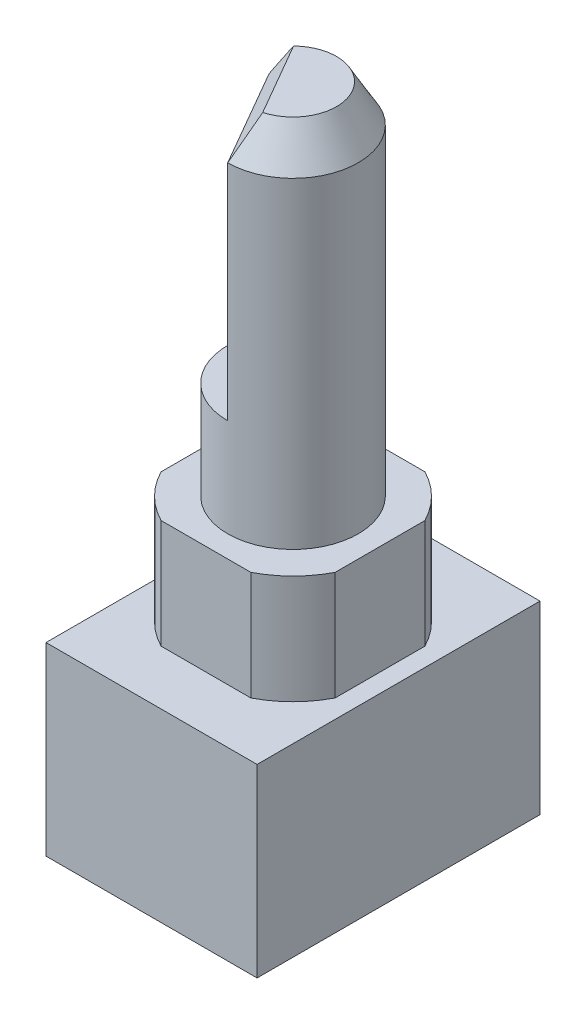
from build123d import *

# Parameters (mm, degrees)
SKETCH1_W           = 9.7
SKETCH1_H           = 13
BOSS_EXTRUDE1_DEPTH = 8.5
SKETCH2_R           = 4.5
BOSS_EXTRUDE2_DEPTH = 5
BOSS_EXTRUDE4_START = -5
SKETCH3_R           = 3
BOSS_EXTRUDE4_DEPTH = 21.5
CUT_EXTRUDE1_DEPTH  = 5
CUT_EXTRUDE2_DEPTH  = 12
CHAMFER1_SIZE       = 1
CHAMFER1_SIZE2      = 1.732050808


with BuildPart() as part:
    # Sketch1 → Boss-Extrude1 (new body)
    with BuildSketch(Plane(origin=(0, 0, 0), x_dir=(1, 0, 0), z_dir=(0, 1, 0))):
        Rectangle(SKETCH1_W, SKETCH1_H)
    extrude(amount=BOSS_EXTRUDE1_DEPTH)

    # Sketch2 → Boss-Extrude2 (add)
    with BuildSketch(Plane(origin=(0, 8.5, 0), x_dir=(1, 0, 0), z_dir=(0, 1, 0))):
        Circle(SKETCH2_R)
    extrude(amount=BOSS_EXTRUDE2_DEPTH)

    # Sketch3 → Boss-Extrude4 (add)
    with BuildSketch(Plane(origin=(0, 13.5, 0), x_dir=(1, 0, 0), z_dir=(0, 1, 0)).offset(BOSS_EXTRUDE4_START)):
        Circle(SKETCH3_R)
    extrude(amount=BOSS_EXTRUDE4_DEPTH)

    # Sketch4 → Cut-Extrude1 (cut)
    with BuildSketch(Plane(origin=(0, 13.5, 0), x_dir=(1, 0, 0), z_dir=(0, 1, 0))):
        with BuildLine():
            ThreePointArc((-4, 2.061552813), (-4.5, 0), (-4, -2.061552813))
            Line((-4, -2.061552813), (-4, 2.061552813))
        make_face()
        with BuildLine():
            ThreePointArc((-2.061552813, -4), (0, -4.5), (2.061552813, -4))
            Line((2.061552813, -4), (-2.061552813, -4))
        make_face()
        with BuildLine():
            Line((4, 2.061552813), (4, -2.061552813))
            ThreePointArc((4, -2.061552813), (4.373213921, -1.060660172), (4.5, 0))
            ThreePointArc((4.5, 0), (4.373213921, 1.060660172), (4, 2.061552813))
        make_face()
        with BuildLine():
            Line((-2.061552813, 4), (2.061552813, 4))
            ThreePointArc((2.061552813, 4), (0, 4.5), (-2.061552813, 4))
        make_face()
    extrude(amount=-CUT_EXTRUDE1_DEPTH, mode=Mode.SUBTRACT)

    # Sketch5 → Cut-Extrude2 (cut)
    with BuildSketch(Plane(origin=(0, 30, 0), x_dir=(1, 0, 0), z_dir=(0, 1, 0))):
        with BuildLine():
            Line((0, -3), (-2.598076211, 1.5))
            ThreePointArc((-2.598076211, 1.5), (-2.598076211, -1.5), (0, -3))
        make_face()
    extrude(amount=-CUT_EXTRUDE2_DEPTH, mode=Mode.SUBTRACT)

    # Chamfer1
    chamfer1_edges = [part.edges().sort_by_distance(p)[0] for p in [
        (0.776457135, 30, -2.897777479),
        (-1.299038106, 30, 0.75),
    ]]
    chamfer1_side = [part.faces().sort_by_distance(p)[0] for p in [
        (0.445120094, 30, -0.256990206),
    ]]
    chamfer(chamfer1_edges, length=CHAMFER1_SIZE, length2=CHAMFER1_SIZE2, reference=chamfer1_side[0])


solid = part.part
